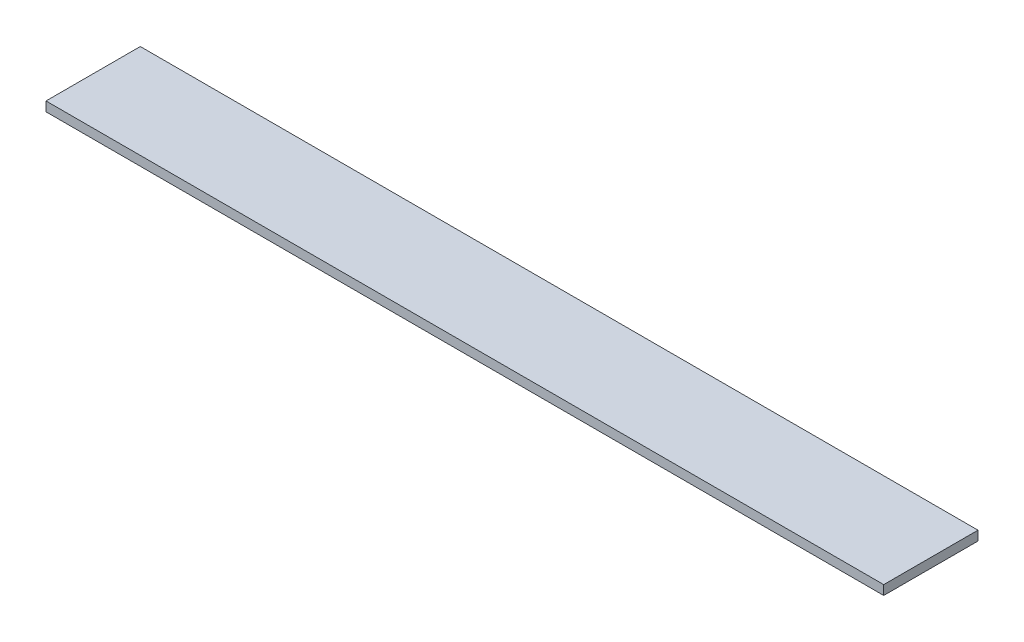
from build123d import *

# Parameters (mm, degrees)
SKETCH1_W           = 888.53
SKETCH1_H           = 100
BOSS_EXTRUDE1_DEPTH = 10


with BuildPart() as part:
    # Sketch1 → Boss-Extrude1 (new body)
    with BuildSketch(Plane(origin=(0, 0, 0), x_dir=(1, 0, 0), z_dir=(0, 1, 0))):
        Rectangle(SKETCH1_W, SKETCH1_H)
    extrude(amount=BOSS_EXTRUDE1_DEPTH)


solid = part.part
